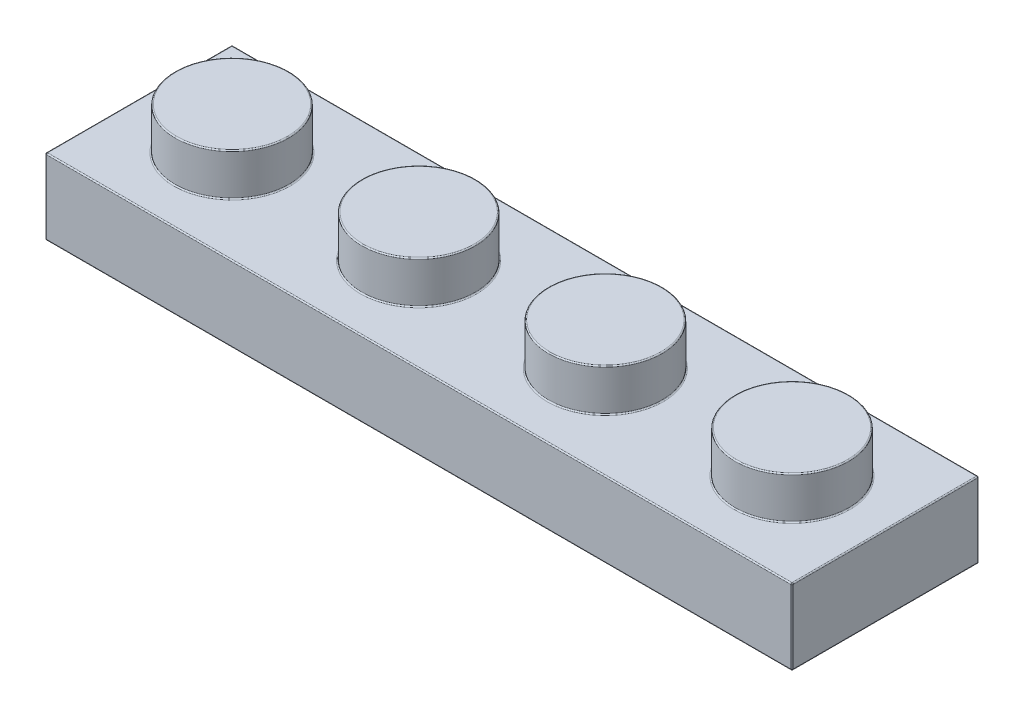
from build123d import *

# Parameters (mm, degrees)
SKETCH1_W       = 7.96
SKETCH1_H       = 7.96
EXTRUDE1_DEPTH  = 3.22
SKETCH2_R       = 2.425
EXTRUDE2_DEPTH  = 1.8
LPATTERN1_COUNT = 4
LPATTERN1_PITCH = 7.96
SHELL1_T        = -1.55
SKETCH3_W       = 28.74
SKETCH3_H       = 4.86
EXTRUDE3_DEPTH  = 0.14
SKETCH5_R       = 1.5
SKETCH5_R_2     = 0.64
EXTRUDE4_DEPTH  = 1.81
FILLET1_R       = 0.05


with BuildPart() as part:
    # Sketch1 → Extrude1 (new body)
    with BuildSketch(Plane(origin=(0, 0, 0), x_dir=(1, 0, 0), z_dir=(0, 1, 0))):
        Rectangle(SKETCH1_W, SKETCH1_H)
    extrude1 = extrude(amount=EXTRUDE1_DEPTH)

    # Sketch2 → Extrude2 (add)
    with BuildSketch(Plane(origin=(0, 3.22, 0), x_dir=(1, 0, 0), z_dir=(0, 1, 0))):
        Circle(SKETCH2_R)
    extrude2 = extrude(amount=EXTRUDE2_DEPTH)

    # LPattern1: Extrude1, Extrude2 ×4
    with Locations(*[(i * LPATTERN1_PITCH, 0, 0) for i in range(1, LPATTERN1_COUNT)]):
        add(extrude1)
        add(extrude2)

    # Shell1
    shell1_openings = [part.faces().sort_by_distance(p)[0] for p in [
        (11.94, 0, 0),
    ]]
    offset(amount=SHELL1_T, openings=shell1_openings, kind=Kind.INTERSECTION)

    # Sketch3 → Extrude3 (cut)
    with BuildSketch(Plane.XZ.offset(-1.67)):
        with Locations((11.94, 0)):
            Rectangle(SKETCH3_W, SKETCH3_H)
    extrude(amount=-EXTRUDE3_DEPTH, mode=Mode.SUBTRACT)

    # Sketch5 → Extrude4 (add)
    with BuildSketch(Plane.XZ.offset(-1.81)):
        with Locations((3.98, 0)):
            Circle(SKETCH5_R)
        with Locations((3.98, 0)):
            Circle(SKETCH5_R_2, mode=Mode.SUBTRACT)
        with Locations((11.94, 0)):
            Circle(SKETCH5_R)
        with Locations((11.94, 0)):
            Circle(SKETCH5_R_2, mode=Mode.SUBTRACT)
        with Locations((19.9, 0)):
            Circle(SKETCH5_R)
        with Locations((19.9, 0)):
            Circle(SKETCH5_R_2, mode=Mode.SUBTRACT)
    extrude(amount=EXTRUDE4_DEPTH)

    # Fillet1
    fillet1_edges = [part.edges().sort_by_distance(p)[0] for p in [
        (-3.98, 3.22, 0),
        (11.94, 3.22, 3.98),
        (-2.425, 3.22, 0),
        (-2.425, 5.02, 0),
        (27.86, 1.61, -3.98),
        (27.86, 3.22, 0),
        (27.86, 0, 0),
        (27.86, 1.61, 3.98),
        (5.535, 3.22, 0),
        (5.535, 5.02, 0),
        (13.495, 3.22, 0),
        (13.495, 5.02, 0),
        (21.455, 3.22, 0),
        (21.455, 5.02, 0),
        (11.94, 0, -2.43),
        (26.31, 0.905, -2.43),
        (-2.43, 0, 0),
        (-2.43, 0.905, -2.43),
        (11.94, 0, 2.43),
        (-2.43, 0.905, 2.43),
        (-0.875, 3.47, 0),
        (26.31, 0, 0),
        (26.31, 0.905, 2.43),
        (7.085, 3.47, 0),
        (15.045, 3.47, 0),
        (23.005, 3.47, 0),
        (11.94, 0, 3.98),
        (-3.98, 0, 0),
        (11.94, 0, -3.98),
        (-0.875, 1.81, 0),
        (7.085, 1.81, 0),
        (15.045, 1.81, 0),
        (23.005, 1.81, 0),
        (11.94, 1.81, 2.43),
        (26.31, 1.81, 0),
        (11.94, 1.81, -2.43),
        (-2.43, 1.81, 0),
        (11.94, 3.22, -3.98),
        (-3.98, 1.61, 3.98),
        (-3.98, 1.61, -3.98),
        (2.48, 1.81, 0),
        (3.34, 1.81, 0),
        (2.48, 0, 0),
        (3.34, 0, 0),
        (10.44, 1.81, 0),
        (11.3, 1.81, 0),
        (10.44, 0, 0),
        (11.3, 0, 0),
        (18.4, 1.81, 0),
        (19.26, 1.81, 0),
        (18.4, 0, 0),
        (19.26, 0, 0),
    ]]
    fillet(fillet1_edges, radius=FILLET1_R)


solid = part.part
